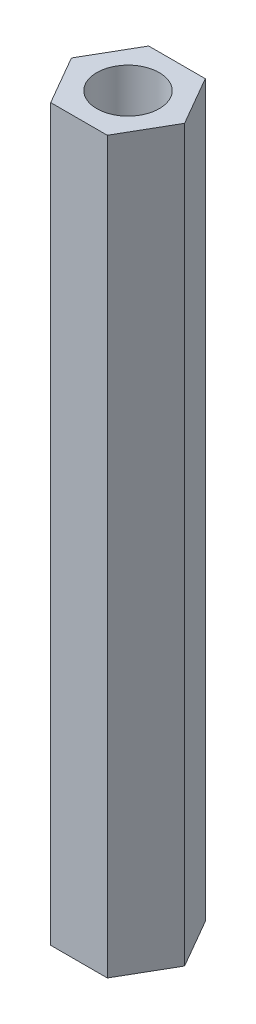
from build123d import *

# Parameters (mm, degrees)
SKETCH_1_R      = 1.5
EXTRUDE_1_DEPTH = 35


with BuildPart() as part:
    # 草图1 → 凸台-拉伸1 (new body)
    with BuildSketch(Plane(origin=(0, 0, 0), x_dir=(1, 0, 0), z_dir=(0, 1, 0))):
        Polygon((2.713546265, 0), (1.356773133, 2.35), (-1.356773133, 2.35), (-2.713546265, 0), (-1.356773133, -2.35), (1.356773133, -2.35), align=None)
        Circle(SKETCH_1_R, mode=Mode.SUBTRACT)
    extrude(amount=EXTRUDE_1_DEPTH)


solid = part.part
